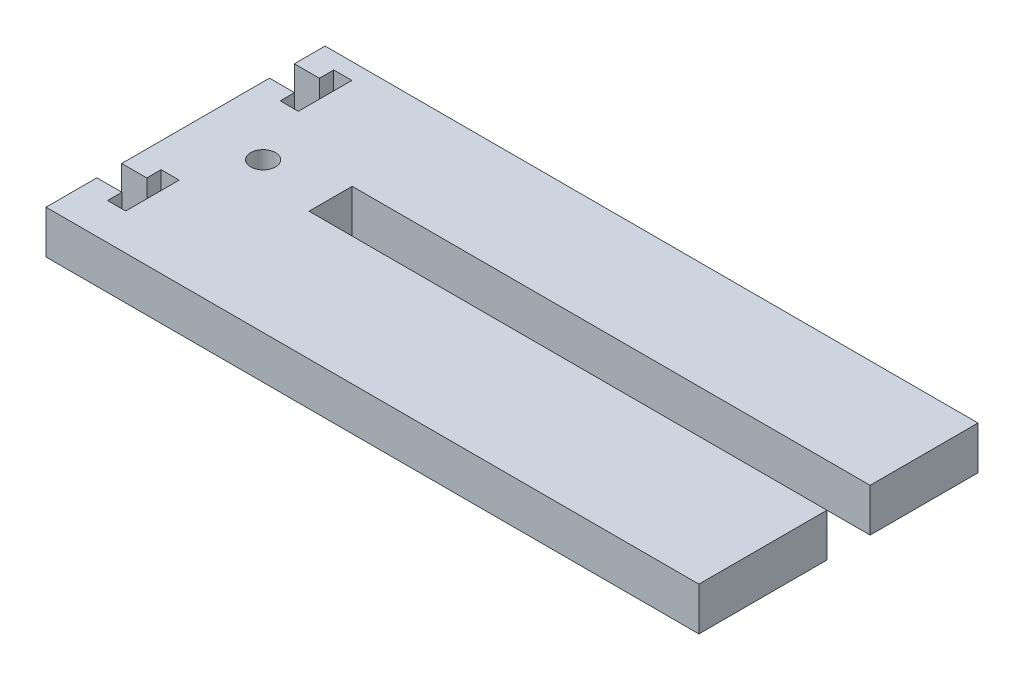
from build123d import *

# Parameters (mm, degrees)
SKETCH1_R               = 1.8288
BOSS_EXTRUDE1_DEPTH     = 6.35
SKETCH2_W               = 96.0628
SKETCH2_H               = 111.337442597
CUT_EXTRUDE1_DEPTH      = 1
CUT_EXTRUDE1_DEPTH_BACK = 7.35


with BuildPart() as part:
    # Sketch1 → Boss-Extrude1 (new body)
    with BuildSketch(Plane(origin=(0, 0, 0), x_dir=(1, 0, 0), z_dir=(0, 1, 0))):
        Polygon((-48.0314, 76.2), (48.0314, 76.2), (48.0314, 60.325), (-28.1686, 60.325), (-28.1686, 53.975), (48.0314, 53.975), (48.0314, 22.225), (-28.1686, 22.225), (-28.1686, 15.875), (48.0314, 15.875), (48.0314, -15.875), (-28.1686, -15.875), (-28.1686, -22.225), (48.0314, -22.225), (48.0314, -53.975), (-28.1686, -53.975), (-28.1686, -60.325), (48.0314, -60.325), (48.0314, -76.2), (-48.0314, -76.2), (-48.0314, -33.5788), (-44.3484, -33.5788), (-44.3484, -35.687), (-41.6814, -35.687), (-41.6814, -27.813), (-44.3484, -27.813), (-44.3484, -29.9212), (-48.0314, -29.9212), (-48.0314, 4.5212), (-44.3484, 4.5212), (-44.3484, 2.413), (-41.6814, 2.413), (-41.6814, 10.287), (-44.3484, 10.287), (-44.3484, 8.1788), (-48.0314, 8.1788), (-48.0314, 42.6212), (-44.3484, 42.6212), (-44.3484, 40.513), (-41.6814, 40.513), (-41.6814, 48.387), (-44.3484, 48.387), (-44.3484, 46.2788), (-48.0314, 46.2788), (-48.0314, 68.0212), (-44.3484, 68.0212), (-44.3484, 65.913), (-41.6814, 65.913), (-41.6814, 73.787), (-44.3484, 73.787), (-44.3484, 71.6788), (-48.0314, 71.6788), align=None)
        with Locations((-38.1, 57.15)):
            Circle(SKETCH1_R, mode=Mode.SUBTRACT)
        with Locations((-38.1, 31.75)):
            Circle(SKETCH1_R, mode=Mode.SUBTRACT)
        with Locations((-38.1, 6.35)):
            Circle(SKETCH1_R, mode=Mode.SUBTRACT)
        with Locations((-38.1, -19.05)):
            Circle(SKETCH1_R, mode=Mode.SUBTRACT)
    extrude(amount=-BOSS_EXTRUDE1_DEPTH)

    # Sketch2 → Cut-Extrude1 (cut, two sides)
    with BuildSketch(Plane(origin=(0, 0, 0), x_dir=(1, 0, 0), z_dir=(0, 1, 0))) as cut_extrude1_sk:
        with Locations((0, -20.531278701)):
            Rectangle(SKETCH2_W, SKETCH2_H)
    extrude(amount=CUT_EXTRUDE1_DEPTH, mode=Mode.SUBTRACT)
    extrude(cut_extrude1_sk.sketch, amount=-CUT_EXTRUDE1_DEPTH_BACK, mode=Mode.SUBTRACT)


solid = part.part
